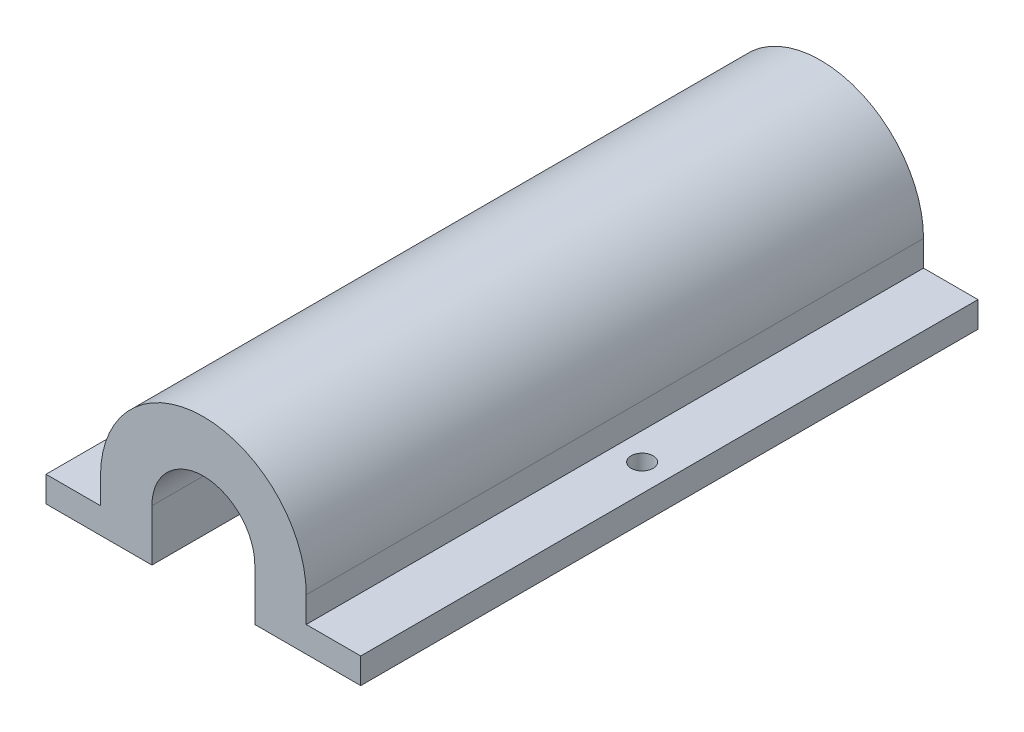
from build123d import *

# Parameters (mm, degrees)
BOSS_EXTRUDE1_DEPTH       = 76.2
TAP_DRILL_FOR_6_32_TAP1_D = 2.7051


with BuildPart() as part:
    # Sketch2 → Boss-Extrude1 (new body)
    with BuildSketch(Plane.XY):
        with BuildLine():
            Line((-19.425899611, -6.35), (-6.35, -6.35))
            Line((-6.35, -6.35), (-6.35, 0))
            ThreePointArc((-6.35, 0), (0, 6.35), (6.35, 0))
            Line((6.35, 0), (6.35, -6.35))
            Line((6.35, -6.35), (19.425899611, -6.35))
            Line((19.425899611, -6.35), (19.425899611, -3.175))
            Line((19.425899611, -3.175), (12.7, -3.175))
            Line((12.7, -3.175), (12.7, 0))
            ThreePointArc((12.7, 0), (0, 12.7), (-12.7, 0))
            Line((-12.7, 0), (-12.7, -3.175))
            Line((-12.7, -3.175), (-19.425899611, -3.175))
            Line((-19.425899611, -3.175), (-19.425899611, -6.35))
        make_face()
    extrude(amount=BOSS_EXTRUDE1_DEPTH)

    # Tap Drill for #6-32 Tap1 (through all)
    with Locations(Plane(origin=(0, -3.175, 0), x_dir=(1, 0, 0), z_dir=(0, 1, 0))):
        with Locations((-16.062949805, -38.1), (16.062949805, -38.1)):
            Hole(TAP_DRILL_FOR_6_32_TAP1_D / 2)


solid = part.part
